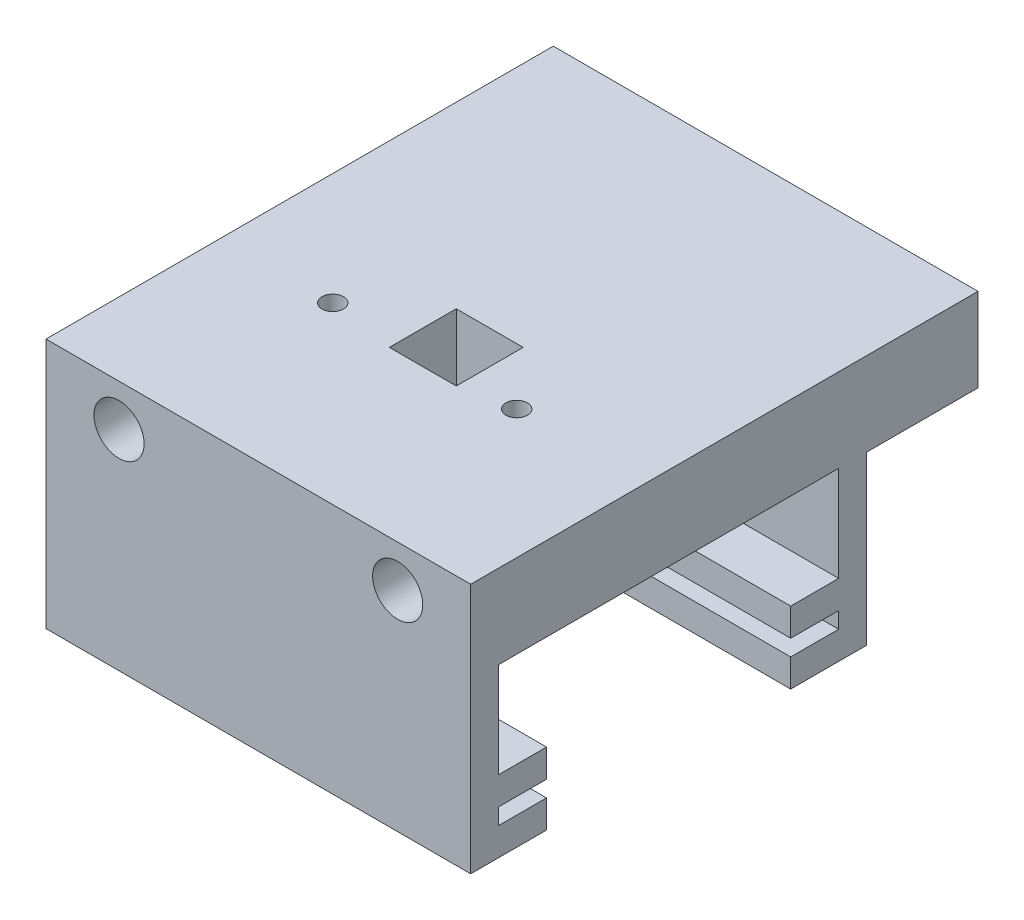
from build123d import *

# Parameters (mm, degrees)
SKETCH2_W                 = 76.2
SKETCH2_H                 = 15
SKETCH2_R                 = 3.96875
TOP_FAILED_HOLES_DEPTH    = 71.02
WALLS_DEPTH               = 45
SKETCH14_R                = 4.5
ROD_HOLES_DEPTH           = 90.746158135
SKETCH15_W                = 71.2
SKETCH15_H                = 8.605
BASE_HOLD_SYRINGE_DEPTH   = 5
SKETCH16_W                = 76.2
SKETCH16_H                = 15
SKETCH16_R                = 4.5
EXTENSION_FOR_MOTOR_DEPTH = 20
TRACK_AND_SCREWS_REACH    = 111.539
SKETCH6_R                 = 1.925
SKETCH6_W                 = 12
SKETCH6_H                 = 12
SECURE_SYRING_REACH       = 126.147
SKETCH18_W                = 8.605
SKETCH18_H                = 5
CUT_EXTRUDE1_REACH        = 126.147
SKETCH22_W                = 11.1
SKETCH22_H                = 43.81
BOSS_EXTRUDE1_DEPTH       = 5


with BuildPart() as part:
    # Sketch2 → Top + failed holes (new body)
    with BuildSketch(Plane.XY):
        with Locations((3, 1.15)):
            Rectangle(SKETCH2_W, SKETCH2_H)
        with Locations((-22, 1.15)):
            Circle(SKETCH2_R, mode=Mode.SUBTRACT)
        with Locations((28, 1.15)):
            Circle(SKETCH2_R, mode=Mode.SUBTRACT)
    extrude(amount=-TOP_FAILED_HOLES_DEPTH)

    # Sketch13 → Walls (add)
    with BuildSketch(Plane(origin=(0, 8.65, 0), x_dir=(1, 0, 0), z_dir=(0, 1, 0))):
        Polygon((-35.1, 71.02), (41.1, 71.02), (41.1, 66.02), (-30.1, 66.02), (-30.1, 5), (41.1, 5), (41.1, 0), (-35.1, 0), align=None)
    extrude(amount=-WALLS_DEPTH)

    # Sketch14 → Rod Holes (cut, through all)
    with BuildSketch(Plane.XY):
        with Locations((-22, 1.15)):
            Circle(SKETCH14_R)
        with Locations((28, 1.15)):
            Circle(SKETCH14_R)
    extrude(amount=-ROD_HOLES_DEPTH, mode=Mode.SUBTRACT)

    # Sketch15 → Base hold syringe (add)
    with BuildSketch(Plane.XZ.offset(36.35)):
        Polygon((41.1, -12.083250566), (41.1, -5), (-30.1, -5), (-30.1, -13.605), (41.1, -13.605), align=None)
        Polygon((41.1, 0), (-35.1, 0), (-35.1, -12.083250566), (-35.1, -13.605), (-30.1, -13.605), (-30.1, -5), (41.1, -5), align=None)
        with Locations((5.5, -61.7175)):
            Rectangle(SKETCH15_W, SKETCH15_H)
        Polygon((-30.1, -57.415), (-35.1, -57.415), (-35.1, -71.02), (41.1, -71.02), (41.1, -66.02), (-30.1, -66.02), align=None)
    extrude(amount=-BASE_HOLD_SYRINGE_DEPTH)

    # Sketch16 → extension for motor (add)
    with BuildSketch(Plane(origin=(0, 0, -71.02), x_dir=(-1, 0, 0), z_dir=(0, 0, -1))):
        with Locations((-3, 1.15)):
            Rectangle(SKETCH16_W, SKETCH16_H)
        with Locations(Location((-28, 1.15, 0), (0, 0, 180))):
            Circle(SKETCH16_R, mode=Mode.SUBTRACT)
        with Locations(Location((22, 1.15, 0), (0, 0, 180))):
            Circle(SKETCH16_R, mode=Mode.SUBTRACT)
    extrude(amount=EXTENSION_FOR_MOTOR_DEPTH)

    # Sketch6 → Track and screws (cut, up to next)
    with BuildSketch(Plane(origin=(0, 8.65, 0), x_dir=(1, 0, 0), z_dir=(0, 1, 0)), mode=Mode.PRIVATE) as track_and_screws_sk1:
        with Locations(Location((18, 31.35, 0), (0, 0, 90))):
            Circle(SKETCH6_R)
    track_and_screws_tool1 = extrude(track_and_screws_sk1.sketch, amount=-TRACK_AND_SCREWS_REACH, mode=Mode.PRIVATE) & part.part
    # Sketch6 → Track and screws (cut, up to next)
    with BuildSketch(Plane(origin=(0, 8.65, 0), x_dir=(1, 0, 0), z_dir=(0, 1, 0)), mode=Mode.PRIVATE) as track_and_screws_sk2:
        with Locations(Location((-15, 31.35, 0), (0, 0, 90))):
            Circle(SKETCH6_R)
    track_and_screws_tool2 = extrude(track_and_screws_sk2.sketch, amount=-TRACK_AND_SCREWS_REACH, mode=Mode.PRIVATE) & part.part
    # Sketch6 → Track and screws (cut, up to next)
    with BuildSketch(Plane(origin=(0, 8.65, 0), x_dir=(1, 0, 0), z_dir=(0, 1, 0)), mode=Mode.PRIVATE) as track_and_screws_sk3:
        with Locations((3, 35.51)):
            Rectangle(SKETCH6_W, SKETCH6_H)
    track_and_screws_tool3 = extrude(track_and_screws_sk3.sketch, amount=-TRACK_AND_SCREWS_REACH, mode=Mode.PRIVATE) & part.part
    add(track_and_screws_tool1.solids().sort_by_distance((18, 8.65, -31.35))[0], mode=Mode.SUBTRACT)
    add(track_and_screws_tool2.solids().sort_by_distance((-15, 8.65, -31.35))[0], mode=Mode.SUBTRACT)
    add(track_and_screws_tool3.solids().sort_by_distance((3, 8.65, -35.51))[0], mode=Mode.SUBTRACT)

    # Sketch18 → Secure syring (add, up to next)
    with BuildSketch(Plane(origin=(41.1, 0, 0), x_dir=(0, 0, -1), z_dir=(1, 0, 0)), mode=Mode.PRIVATE) as secure_syring_sk1:
        with Locations((9.3025, -25.95)):
            Rectangle(SKETCH18_W, SKETCH18_H)
    secure_syring_tool1 = extrude(secure_syring_sk1.sketch, amount=-SECURE_SYRING_REACH, mode=Mode.PRIVATE) - part.part
    # Sketch18 → Secure syring (add, up to next)
    with BuildSketch(Plane(origin=(41.1, 0, 0), x_dir=(0, 0, -1), z_dir=(1, 0, 0)), mode=Mode.PRIVATE) as secure_syring_sk2:
        with Locations((61.7175, -25.95)):
            Rectangle(SKETCH18_W, SKETCH18_H)
    secure_syring_tool2 = extrude(secure_syring_sk2.sketch, amount=-SECURE_SYRING_REACH, mode=Mode.PRIVATE) - part.part
    add(secure_syring_tool1.solids().sort_by_distance((41.1, -25.95, -9.3025))[0])
    add(secure_syring_tool2.solids().sort_by_distance((41.1, -25.95, -61.7175))[0])

    # Sketch21 → Cut-Extrude1 (cut, up to next)
    with BuildSketch(Plane.ZY.offset(35.1), mode=Mode.PRIVATE) as cut_extrude1_sk1:
        with BuildLine():
            Line((-45.51, -28.910046273), (-25.51, -28.910046273))
            ThreePointArc((-25.51, -28.910046273), (-15.221854007, -18.62190028), (-25.51, -8.333754287))
            Line((-25.51, -8.333754287), (-45.51, -8.333754287))
            ThreePointArc((-45.51, -8.333754287), (-55.798145993, -18.62190028), (-45.51, -28.910046273))
        make_face()
    cut_extrude1_tool1 = extrude(cut_extrude1_sk1.sketch, amount=-CUT_EXTRUDE1_REACH, mode=Mode.PRIVATE) & part.part
    add(cut_extrude1_tool1.solids().sort_by_distance((-35.1, -18.6219, -35.51))[0], mode=Mode.SUBTRACT)


with BuildPart() as body_2:
    # Sketch22 → Boss-Extrude1 (new body)
    with BuildSketch(Plane.XZ.offset(36.35)):
        with Locations((-24.55, -35.51)):
            Rectangle(SKETCH22_W, SKETCH22_H)
    extrude(amount=-BOSS_EXTRUDE1_DEPTH)


solid = Compound([part.part, body_2.part])
